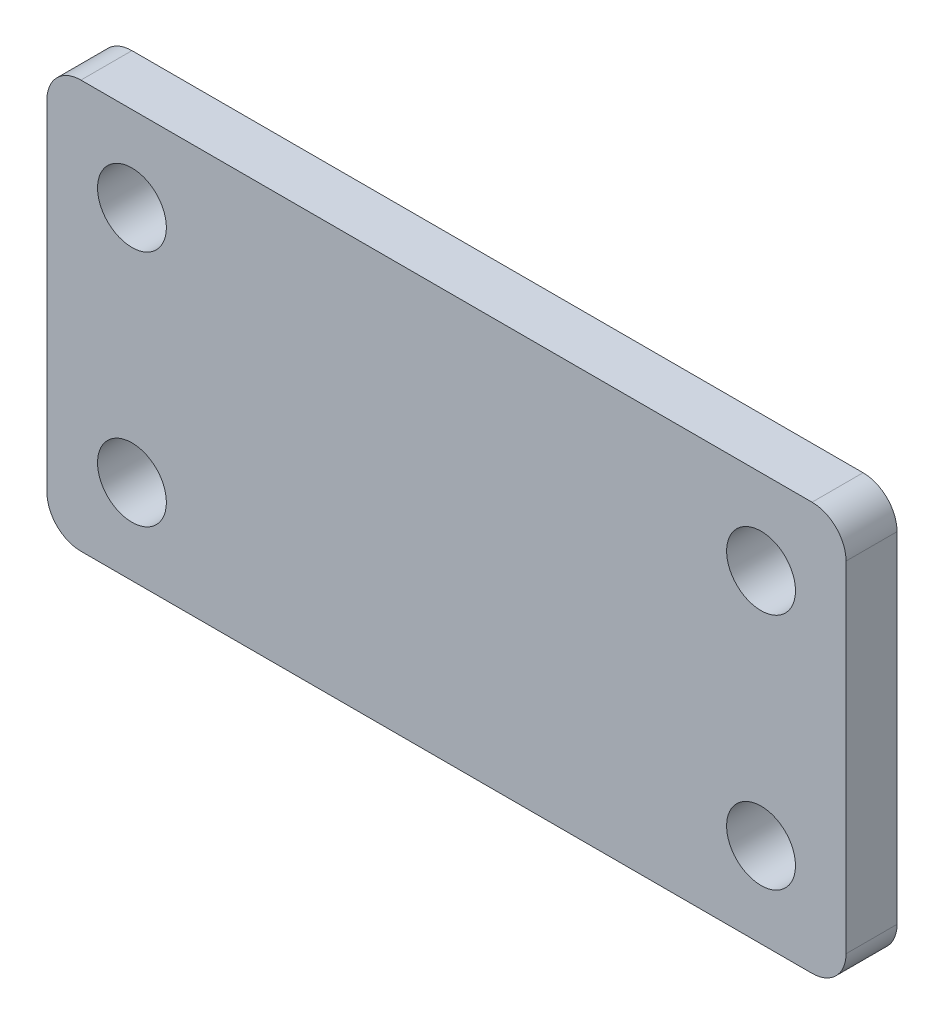
from build123d import *

# Parameters (mm, degrees)
SKETCH_1_W      = 47
SKETCH_1_H      = 24
SKETCH_1_R      = 2.025
EXTRUDE_1_DEPTH = 3
FILLET_1_R      = 2


with BuildPart() as part:
    # 草图1 → 凸台-拉伸1 (new body)
    with BuildSketch(Plane.XY):
        Rectangle(SKETCH_1_W, SKETCH_1_H)
        with Locations((18.5, 7)):
            Circle(SKETCH_1_R, mode=Mode.SUBTRACT)
        with Locations((-18.5, 7)):
            Circle(SKETCH_1_R, mode=Mode.SUBTRACT)
        with Locations((-18.5, -7)):
            Circle(SKETCH_1_R, mode=Mode.SUBTRACT)
        with Locations((18.5, -7)):
            Circle(SKETCH_1_R, mode=Mode.SUBTRACT)
    extrude(amount=EXTRUDE_1_DEPTH)

    # 圆角1
    fillet_1_edges = [part.edges().sort_by_distance(p)[0] for p in [
        (23.5, -12, 1.5),
        (-23.5, -12, 1.5),
        (-23.5, 12, 1.5),
        (23.5, 12, 1.5),
    ]]
    fillet(fillet_1_edges, radius=FILLET_1_R)


solid = part.part
